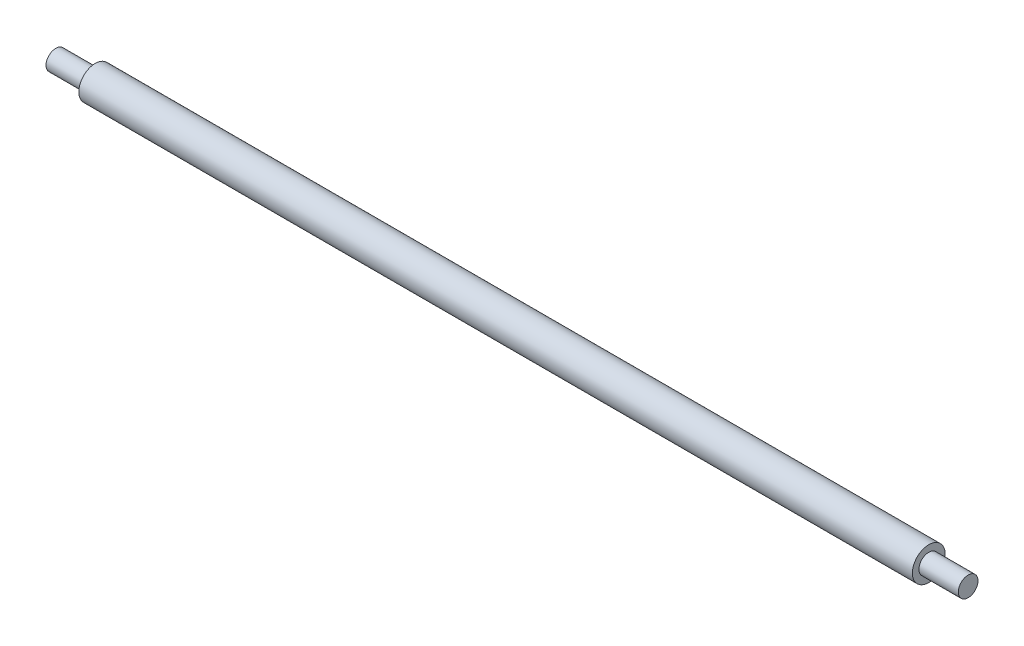
from build123d import *

# Parameters (mm, degrees)
SKETCH1_R           = 2.5
BOSS_EXTRUDE1_DEPTH = 63.5
SKETCH2_R           = 1.5
BOSS_EXTRUDE2_DEPTH = 6
SKETCH3_R           = 1.5
BOSS_EXTRUDE3_DEPTH = 6


with BuildPart() as part:
    # Sketch1 → Boss-Extrude1 (new body, symmetric)
    with BuildSketch(Plane(origin=(0, 0, 0), x_dir=(0, 0, -1), z_dir=(1, 0, 0))):
        Circle(SKETCH1_R)
    extrude(amount=BOSS_EXTRUDE1_DEPTH, both=True)

    # Sketch2 → Boss-Extrude2 (add)
    with BuildSketch(Plane(origin=(63.5, 0, 0), x_dir=(0, 0, -1), z_dir=(1, 0, 0))):
        Circle(SKETCH2_R)
    extrude(amount=BOSS_EXTRUDE2_DEPTH)

    # Sketch3 → Boss-Extrude3 (add)
    with BuildSketch(Plane.ZY.offset(63.5)):
        Circle(SKETCH3_R)
    extrude(amount=BOSS_EXTRUDE3_DEPTH)


solid = part.part
